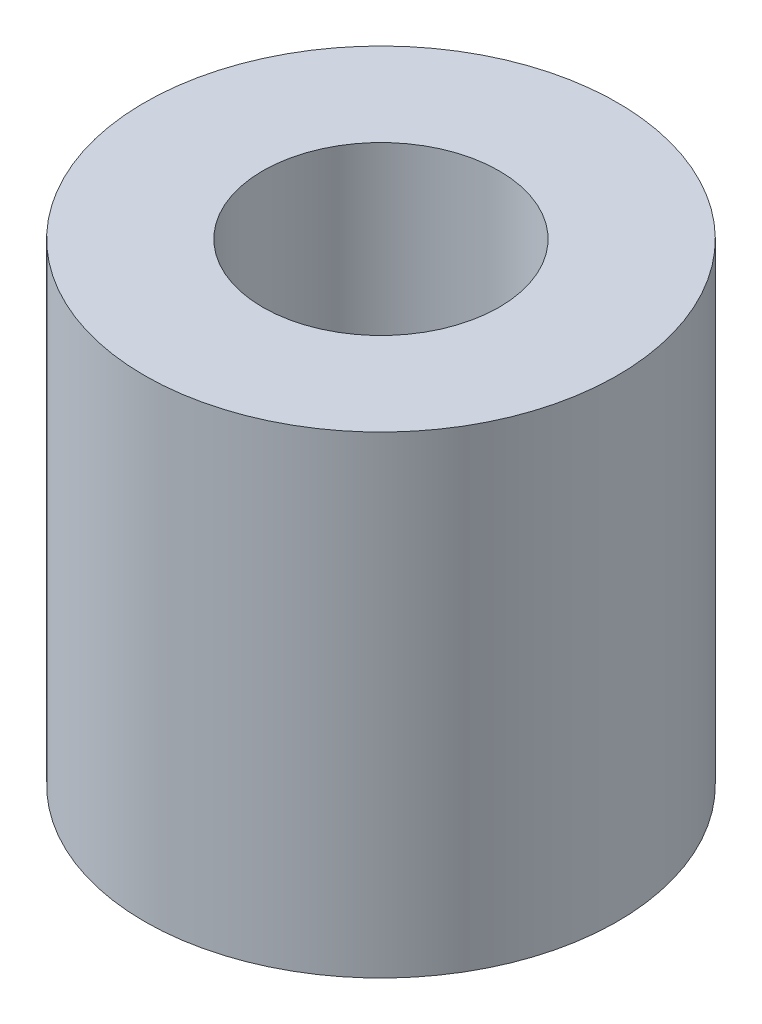
from build123d import *

# Parameters (mm, degrees)
SKETCH1_R           = 6.35
SKETCH1_R_2         = 3.175
BOSS_EXTRUDE1_DEPTH = 12.7


with BuildPart() as part:
    # Sketch1 → Boss-Extrude1 (new body)
    with BuildSketch(Plane(origin=(0, 0, 0), x_dir=(1, 0, 0), z_dir=(0, 1, 0))):
        Circle(SKETCH1_R)
        Circle(SKETCH1_R_2, mode=Mode.SUBTRACT)
    extrude(amount=BOSS_EXTRUDE1_DEPTH)


solid = part.part
